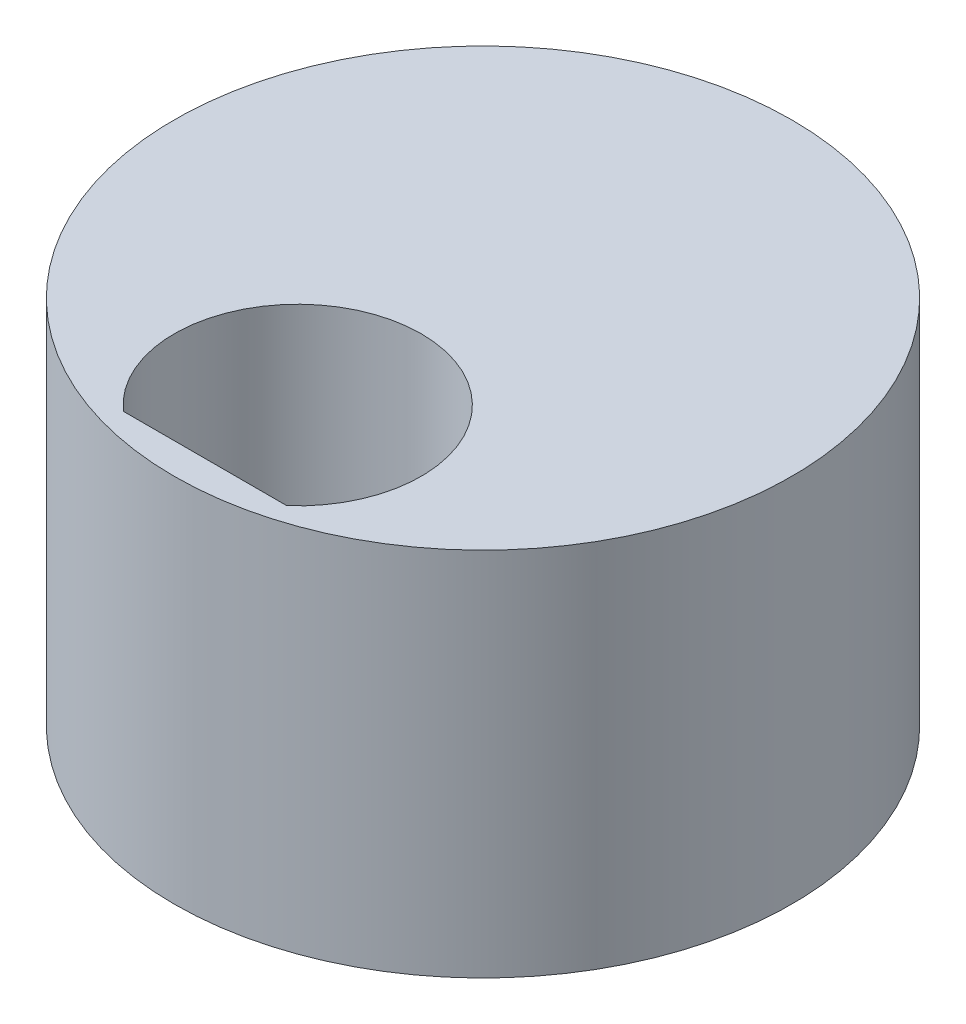
from build123d import *

# Parameters (mm, degrees)
SKETCH1_R           = 5
BOSS_EXTRUDE1_DEPTH = 6


with BuildPart() as part:
    # Sketch1 → Boss-Extrude1 (new body)
    with BuildSketch(Plane(origin=(0, 0, 0), x_dir=(1, 0, 0), z_dir=(0, 1, 0))):
        Circle(SKETCH1_R)
        with BuildLine():
            Line((1.322875656, -4.5), (-1.322875656, -4.5))
            ThreePointArc((-1.322875656, -4.5), (0, -1), (1.322875656, -4.5))
        make_face(mode=Mode.SUBTRACT)
    extrude(amount=BOSS_EXTRUDE1_DEPTH)


solid = part.part
